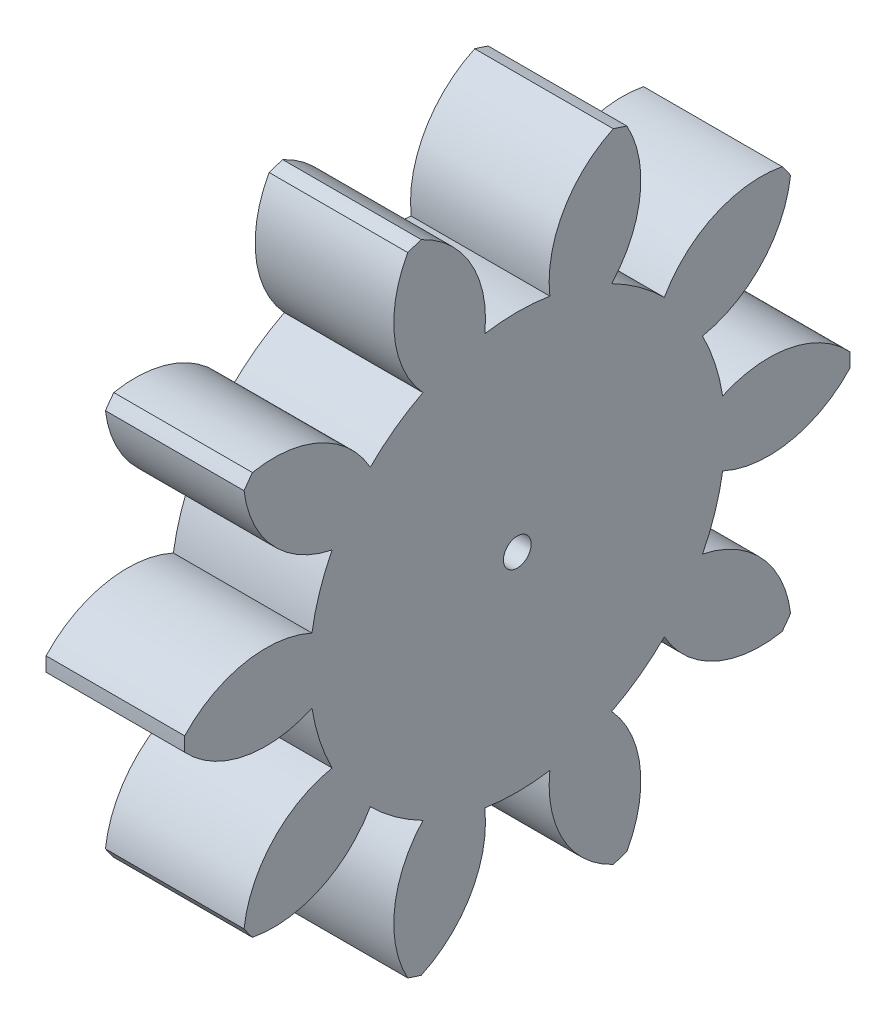
from build123d import *

# Parameters (mm, degrees)
BASPROSKE_W     = 5
BASPROSKE_H     = 12
TOOTHCUT_DEPTH  = 18.691806013
TEETHCUTS_COUNT = 10
TEETHCUTS_ANGLE = 324
BORSKE_R        = 0.5
BORE_DEPTH      = 50.0000508


with BuildPart() as part:
    # BasProSke → Base-Revolve (revolve)
    with BuildSketch(Plane(origin=(0, 0, 0), x_dir=(1, 0, 0), z_dir=(0, 1, 0)), mode=Mode.PRIVATE) as base_revolve_sk:
        with Locations((2.5, 6)):
            Rectangle(BASPROSKE_W, BASPROSKE_H)
    revolve(base_revolve_sk.sketch.rotate(Axis((-10, 0, 0), (1, 0, 0)), 180), axis=Axis((-10, 0, 0), (1, 0, 0)))

    # TooCutSke → ToothCut (cut, through all)
    with BuildSketch(Plane(origin=(0, 0, 0), x_dir=(0, 0, -1), z_dir=(1, 0, 0))):
        with BuildLine():
            ThreePointArc((1.173662691, 7.406586048), (0, 7.499), (-1.173662691, 7.406586048))
            ThreePointArc((-1.173662691, 7.406586048), (-1.668191438, 9.834565786), (-3.497907776, 11.50542856))
            ThreePointArc((-3.497907776, 11.50542856), (0, 12.0254), (3.497907776, 11.50542856))
            ThreePointArc((3.497907776, 11.50542856), (1.668191438, 9.834565786), (1.173662691, 7.406586048))
        make_face()
    toothcut = extrude(amount=TOOTHCUT_DEPTH, mode=Mode.SUBTRACT)

    # TeethCuts: ToothCut ×10 about axis
    teethcuts_axis = Axis((-10, 0, 0), (1, 0, 0))
    for i in range(1, TEETHCUTS_COUNT):
        add(toothcut.rotate(teethcuts_axis, i * TEETHCUTS_ANGLE / (TEETHCUTS_COUNT - 1)), mode=Mode.SUBTRACT)

    # BorSke → Bore (cut, symmetric)
    with BuildSketch(Plane(origin=(0, 0, 0), x_dir=(0, 0, -1), z_dir=(1, 0, 0))):
        with Locations(Location((0, 0, 0), (0, 0, 180))):
            Circle(BORSKE_R)
    extrude(amount=BORE_DEPTH, both=True, mode=Mode.SUBTRACT)


solid = part.part
